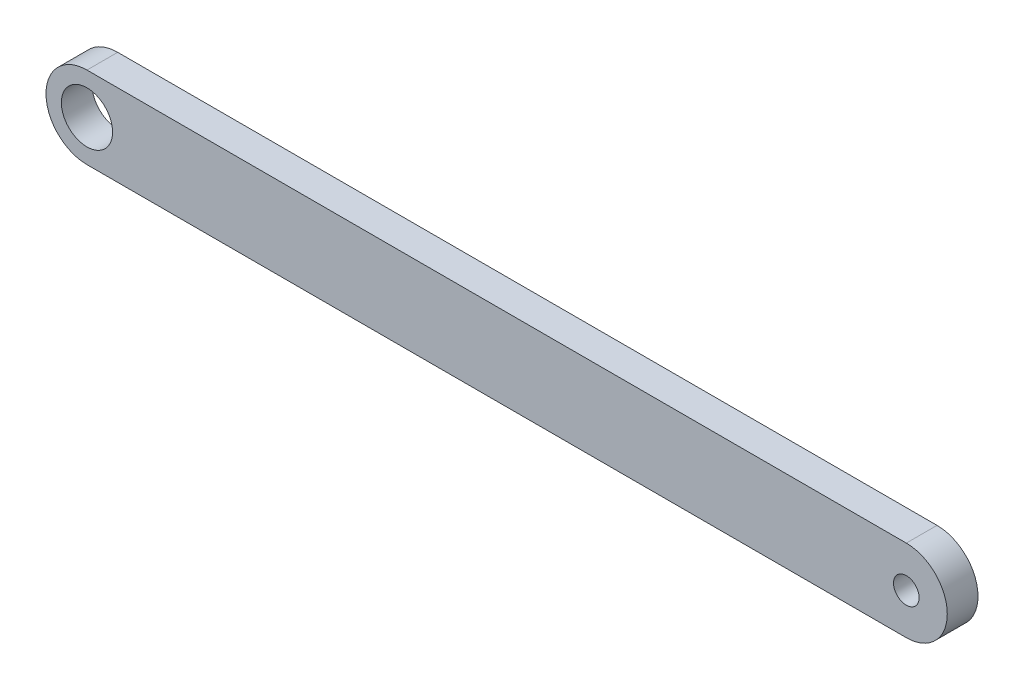
from build123d import *

# Parameters (mm, degrees)
CROQUIS1_R              = 5
CROQUIS1_R_2            = 2.5
SALIENTE_EXTRUIR1_DEPTH = 6


with BuildPart() as part:
    # Croquis1 → Saliente-Extruir1 (new body)
    with BuildSketch(Plane.XY):
        with BuildLine():
            Line((-54.371028707, 8), (105.628971293, 8))
            ThreePointArc((105.628971293, 8), (113.628971293, 0), (105.628971293, -8))
            Line((105.628971293, -8), (-54.371028707, -8))
            ThreePointArc((-54.371028707, -8), (-62.371028707, 0), (-54.371028707, 8))
        make_face()
        with Locations((-54.371028707, 0)):
            Circle(CROQUIS1_R, mode=Mode.SUBTRACT)
        with Locations((105.628971293, 0)):
            Circle(CROQUIS1_R_2, mode=Mode.SUBTRACT)
    extrude(amount=SALIENTE_EXTRUIR1_DEPTH)


solid = part.part
